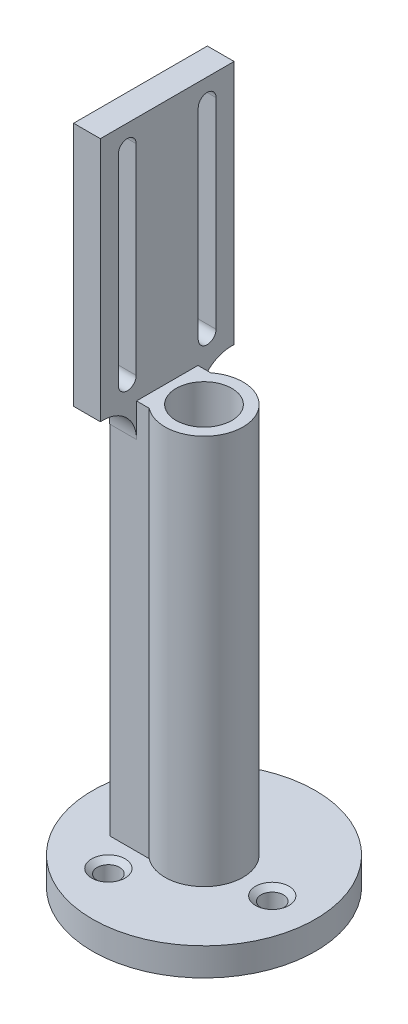
from build123d import *

# Parameters (mm, degrees)
F_1_4_20_TAPPED_HOLE1_D           = 5.1054
F_1_4_20_TAPPED_HOLE1_CSINK_D     = 7.62
F_1_4_20_TAPPED_HOLE1_CSINK_ANGLE = 100
BOSS_EXTRUDE1_DEPTH               = 88.9
SKETCH13_W                        = 6.096
SKETCH13_H                        = 30.48
BOSS_EXTRUDE2_DEPTH               = 55.88
CUT_EXTRUDE1_REACH                = 19.018
FILLET1_R                         = 7.62


with BuildPart() as part:
    # Sketch1 → Revolve1 (revolve)
    with BuildSketch(Plane.XY):
        Polygon((6.35, 19.05), (25.4, 19.05), (25.4, 25.4), (8.89, 25.4), (8.89, 114.3), (6.35, 114.3), align=None)
    revolve(axis=Axis((0, 131.17698584, 0), (0, -1, 0)))

    # 1/4-20 Tapped Hole1 (through all)
    with Locations(Plane(origin=(0, 25.4, 0), x_dir=(1, 0, 0), z_dir=(0, 1, 0))):
        with Locations((-8.212314406, -13.58578364), (-7.659476559, 13.904964719), (15.871790965, -0.319181079)):
            CounterSinkHole(F_1_4_20_TAPPED_HOLE1_D / 2, F_1_4_20_TAPPED_HOLE1_CSINK_D / 2, counter_sink_angle=F_1_4_20_TAPPED_HOLE1_CSINK_ANGLE)

    # Sketch12 → Boss-Extrude1 (add)
    with BuildSketch(Plane(origin=(0, 25.4, 0), x_dir=(1, 0, 0), z_dir=(0, 1, 0))):
        with BuildLine():
            Line((-5.480155107, -7), (-14.478, -7))
            Line((-14.478, -7), (-14.478, 7))
            Line((-14.478, 7), (-5.480155107, 7))
            ThreePointArc((-5.480155107, 7), (-8.89, 0), (-5.480155107, -7))
        make_face()
    extrude(amount=BOSS_EXTRUDE1_DEPTH)

    # Sketch13 → Boss-Extrude2 (add)
    with BuildSketch(Plane(origin=(0, 114.3, 0), x_dir=(1, 0, 0), z_dir=(0, 1, 0))):
        with Locations((-11.43, 0)):
            Rectangle(SKETCH13_W, SKETCH13_H)
    extrude(amount=BOSS_EXTRUDE2_DEPTH)

    # Sketch15 → Cut-Extrude1 (cut, up to next)
    with BuildSketch(Plane(origin=(-8.382, 0, 0), x_dir=(0, 0, -1), z_dir=(1, 0, 0)), mode=Mode.PRIVATE) as cut_extrude1_sk1:
        with BuildLine():
            Line((-11.132, 119.38), (-11.132, 165.1))
            ThreePointArc((-11.132, 165.1), (-9.1, 167.132), (-7.068, 165.1))
            Line((-7.068, 165.1), (-7.068, 119.38))
            ThreePointArc((-7.068, 119.38), (-9.1, 117.348), (-11.132, 119.38))
        make_face()
    cut_extrude1_tool1 = extrude(cut_extrude1_sk1.sketch, amount=-CUT_EXTRUDE1_REACH, mode=Mode.PRIVATE) & part.part
    add(cut_extrude1_tool1.solids().sort_by_distance((-8.382, 142.24, 9.1))[0], mode=Mode.SUBTRACT)
    # Sketch15 → Cut-Extrude1 (cut, up to next)
    with BuildSketch(Plane(origin=(-8.382, 0, 0), x_dir=(0, 0, -1), z_dir=(1, 0, 0)), mode=Mode.PRIVATE) as cut_extrude1_sk2:
        with BuildLine():
            Line((11.132, 119.38), (11.132, 165.1))
            ThreePointArc((11.132, 165.1), (9.1, 167.132), (7.068, 165.1))
            Line((7.068, 165.1), (7.068, 119.38))
            ThreePointArc((7.068, 119.38), (9.1, 117.348), (11.132, 119.38))
        make_face()
    cut_extrude1_tool2 = extrude(cut_extrude1_sk2.sketch, amount=-CUT_EXTRUDE1_REACH, mode=Mode.PRIVATE) & part.part
    add(cut_extrude1_tool2.solids().sort_by_distance((-8.382, 142.24, -9.1))[0], mode=Mode.SUBTRACT)

    # Fillet1
    fillet1_edges = [part.edges().sort_by_distance(p)[0] for p in [
        (-11.43, 114.3, 7),
        (-11.43, 114.3, -7),
    ]]
    fillet(fillet1_edges, radius=FILLET1_R)


solid = part.part
